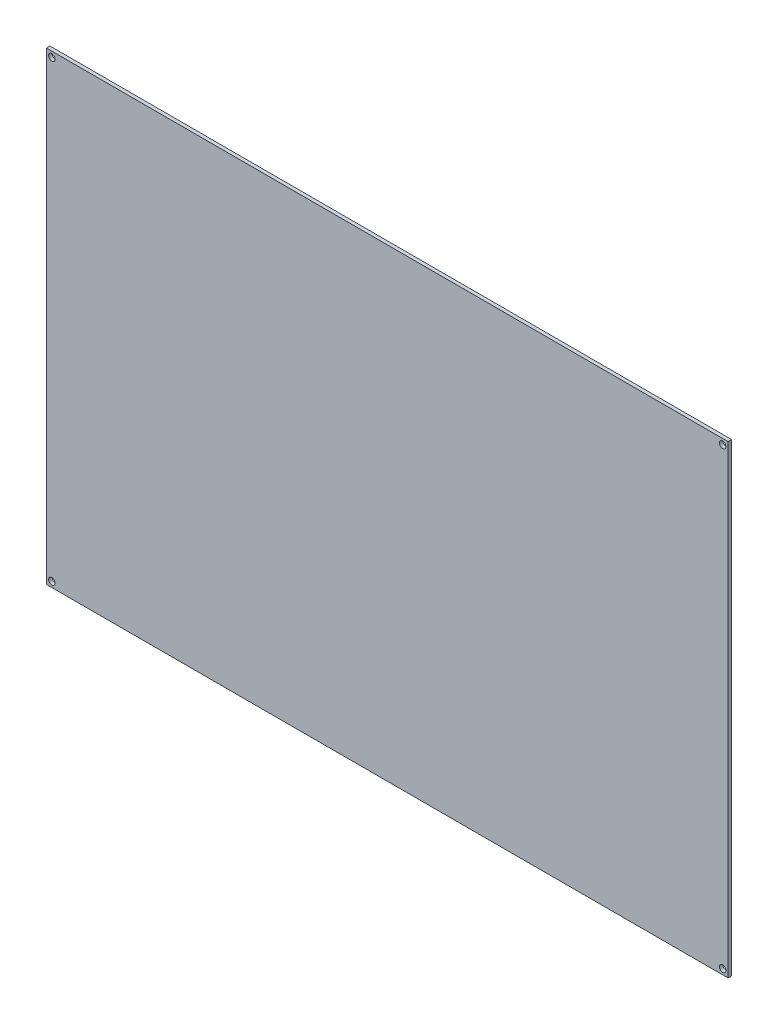
from build123d import *

# Parameters (mm, degrees)
SCHIZZO1_W     = 314
SCHIZZO1_H     = 214
SCHIZZO1_R     = 1.5
EXTRUDE1_DEPTH = 1.6


with BuildPart() as part:
    # Schizzo1 → Extrude1 (new body)
    with BuildSketch(Plane.XY):
        with Locations((157, 107)):
            Rectangle(SCHIZZO1_W, SCHIZZO1_H)
        with Locations((2.5, 211.5)):
            Circle(SCHIZZO1_R, mode=Mode.SUBTRACT)
        with Locations((311.5, 211.5)):
            Circle(SCHIZZO1_R, mode=Mode.SUBTRACT)
        with Locations((2.5, 2.5)):
            Circle(SCHIZZO1_R, mode=Mode.SUBTRACT)
        with Locations((311.5, 2.5)):
            Circle(SCHIZZO1_R, mode=Mode.SUBTRACT)
    extrude(amount=-EXTRUDE1_DEPTH)


solid = part.part
